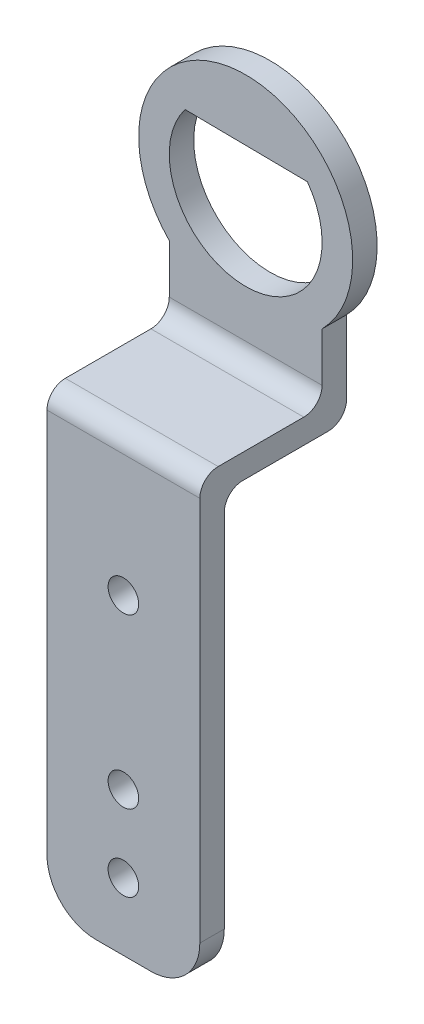
from build123d import *

# Parameters (mm, degrees)
BOSS_EXTRUDE1_DEPTH = 0.4
SKETCH2_W           = 2.5
SKETCH2_H           = 0.4
BOSS_EXTRUDE2_DEPTH = 2
SKETCH3_W           = 2.5
SKETCH3_H           = 0.4
BOSS_EXTRUDE3_DEPTH = 7
FILLET1_R           = 0.3
FILLET2_R           = 0.8
SKETCH4_R           = 0.25
CUT_EXTRUDE1_DEPTH  = 4


with BuildPart() as part:
    # Sketch1 → Boss-Extrude1 (new body)
    with BuildSketch(Plane.XY):
        with BuildLine():
            Line((0.266025337, -2.019252852), (0.266025337, -3.519252852))
            Line((0.266025337, -3.519252852), (2.766025337, -3.519252852))
            Line((2.766025337, -3.519252852), (2.766025337, -2.019252852))
            ThreePointArc((2.766025337, -2.019252852), (1.516025337, 0.955492019), (0.266025337, -2.019252852))
        make_face()
        with BuildLine():
            Line((2.524676695, -0.056183906), (0.524811845, -0.032933419))
            ThreePointArc((0.524811845, -0.032933419), (1.501493783, -2.044423511), (2.524676695, -0.056183906))
        make_face(mode=Mode.SUBTRACT)
    extrude(amount=BOSS_EXTRUDE1_DEPTH)

    # Sketch2 → Boss-Extrude2 (add)
    with BuildSketch(Plane.XY.offset(0.4)):
        with Locations((1.516025337, -3.319252852)):
            Rectangle(SKETCH2_W, SKETCH2_H)
    extrude(amount=BOSS_EXTRUDE2_DEPTH)

    # Sketch3 → Boss-Extrude3 (add)
    with BuildSketch(Plane.XZ.offset(3.519252852)):
        with Locations((1.516025337, 2.2)):
            Rectangle(SKETCH3_W, SKETCH3_H)
    extrude(amount=BOSS_EXTRUDE3_DEPTH)

    # Fillet1
    fillet1_edges = [part.edges().sort_by_distance(p)[0] for p in [
        (1.516025337, -3.119252852, 0.4),
        (1.516025337, -3.119252852, 2.4),
        (1.516025337, -3.519252852, 2),
        (1.516025337, -3.519252852, 0),
    ]]
    fillet(fillet1_edges, radius=FILLET1_R)

    # Fillet2
    fillet2_edges = [part.edges().sort_by_distance(p)[0] for p in [
        (0.266025337, -10.519252852, 2.2),
        (2.766025337, -10.519252852, 2.2),
    ]]
    fillet(fillet2_edges, radius=FILLET2_R)

    # Sketch4 → Cut-Extrude1 (cut)
    with BuildSketch(Plane.XY.offset(2.4)):
        with Locations((1.516025337, -5.419252852)):
            Circle(SKETCH4_R)
        with Locations((1.516025337, -9.419252852)):
            Circle(SKETCH4_R)
        with Locations((1.516025337, -8.169252852)):
            Circle(SKETCH4_R)
    extrude(amount=-CUT_EXTRUDE1_DEPTH, mode=Mode.SUBTRACT)


solid = part.part
